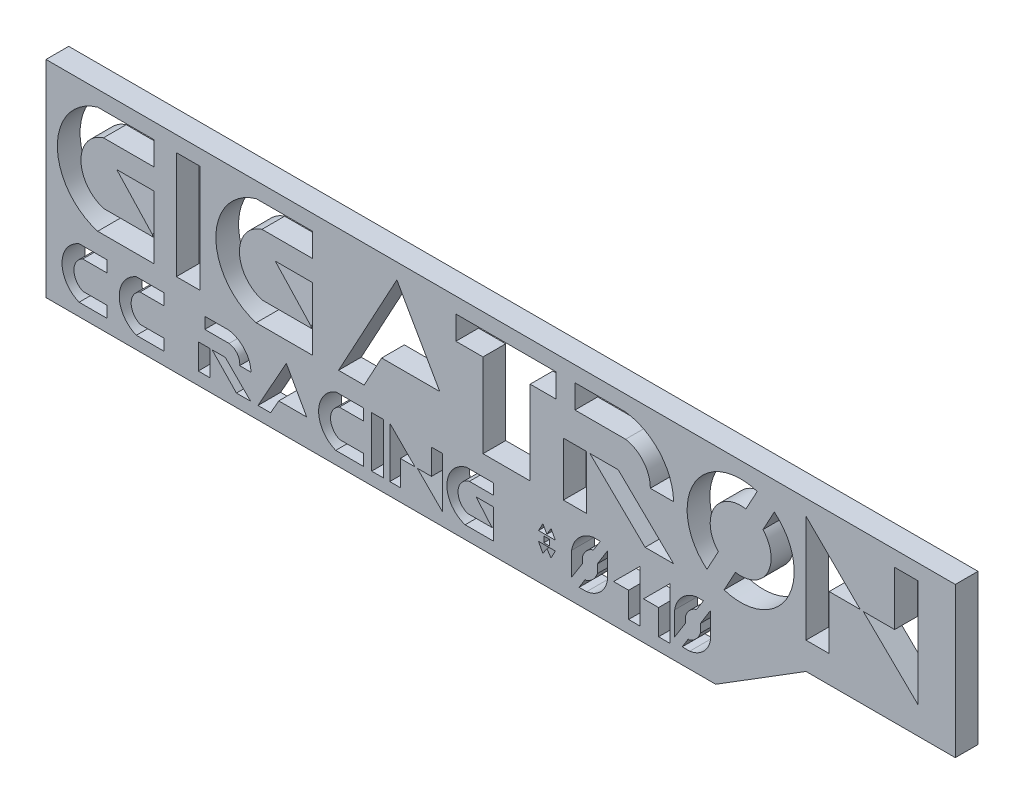
from build123d import *

# Parameters (mm, degrees)
SKETCH1_R           = 2.993573696
SKETCH1_W           = 1.32394335
SKETCH1_H           = 6.009004725
SKETCH1_W_2         = 1.302821584
SKETCH1_H_2         = 3.004502363
SKETCH1_W_3         = 0.319555978
SKETCH1_H_3         = 0.32630106
SKETCH1_W_4         = 0.655123172
SKETCH1_H_4         = 1.417072294
SKETCH1_W_5         = 0.651285311
SKETCH1_H_5         = 2.834144587
BOSS_EXTRUDE1_DEPTH = 1.27
BOSS_EXTRUDE2_DEPTH = 1.27


with BuildPart() as part:
    # Sketch1 → Boss-Extrude1 (new body)
    with BuildSketch(Plane.XY):
        Polygon((0, 8.391688266), (50.853628484, 8.391688266), (50.853628484, 0), (42.503409949, 0), (37.456123998, -3.144988604), (0, -3.144988604), align=None)
        with Locations((38.849727057, 4.508958957)):
            Circle(SKETCH1_R, mode=Mode.SUBTRACT)
        with BuildLine():
            Line((6.036873502, 7.524389986), (6.036873502, 6.203444982))
            Line((6.036873502, 6.203444982), (3.213677316, 6.203444982))
            ThreePointArc((3.213677316, 6.203444982), (1.954325424, 4.493986741), (3.213677316, 2.7845285))
            Line((3.213677316, 2.7845285), (5.943527585, 2.7845285))
            Line((5.943527585, 2.7845285), (5.943527585, 2.895958274))
            Line((5.943527585, 2.895958274), (3.956778712, 5.036610228))
            Line((3.956778712, 5.036610228), (6.036873502, 5.036610228))
            Line((6.036873502, 5.036610228), (6.036873502, 1.515385261))
            Line((6.036873502, 1.515385261), (2.889916286, 1.515385261))
            ThreePointArc((2.889916286, 1.515385261), (0.635162123, 4.519887624), (2.889916286, 7.524389986))
            Line((2.889916286, 7.524389986), (6.036873502, 7.524389986))
        make_face(mode=Mode.SUBTRACT)
        with Locations((7.952259717, 4.519887623)):
            Rectangle(SKETCH1_W, SKETCH1_H, mode=Mode.SUBTRACT)
        with BuildLine():
            Line((12.078277316, 2.7845285), (14.808127585, 2.7845285))
            Line((14.808127585, 2.7845285), (14.808127585, 2.895958274))
            Line((14.808127585, 2.895958274), (12.821378712, 5.036610228))
            Line((12.821378712, 5.036610228), (14.901473502, 5.036610228))
            Line((14.901473502, 5.036610228), (14.901473502, 1.515385261))
            Line((14.901473502, 1.515385261), (11.754516286, 1.515385261))
            ThreePointArc((11.754516286, 1.515385261), (9.499762123, 4.519887624), (11.754516286, 7.524389986))
            Line((11.754516286, 7.524389986), (14.901473502, 7.524389986))
            Line((14.901473502, 7.524389986), (14.901473502, 6.203444982))
            Line((14.901473502, 6.203444982), (12.078277316, 6.203444982))
            ThreePointArc((12.078277316, 6.203444982), (10.818925424, 4.493986741), (12.078277316, 2.7845285))
        make_face(mode=Mode.SUBTRACT)
        Polygon((16.359979161, 1.515385261), (19.621874677, 7.524389986), (22.022205075, 3.31809951), (18.771757662, 3.31809951), (17.793182041, 1.515385261), align=None, mode=Mode.SUBTRACT)
        Polygon((22.922328974, 6.203444982), (22.922328974, 7.524389986), (28.523099902, 7.524389986), (28.523099902, 6.203444982), (27.078426164, 6.203444982), (27.078426164, 1.515385261), (24.439204434, 1.515385261), (24.439204434, 6.203444982), align=None, mode=Mode.SUBTRACT)
        with Locations((29.583857286, 3.017636442)):
            Rectangle(SKETCH1_W_2, SKETCH1_H_2, mode=Mode.SUBTRACT)
        Polygon((30.413320868, 4.519887624), (33.505985808, 1.515385261), (35.098913964, 1.515385261), (32.006249025, 4.519887624), align=None, mode=Mode.SUBTRACT)
        with BuildLine():
            Line((29.583857286, 7.524389986), (29.583857286, 6.203444982))
            Line((29.583857286, 6.203444982), (32.413769336, 6.203444982))
            ThreePointArc((32.413769336, 6.203444982), (33.415640705, 5.616672439), (33.796575511, 4.519887624))
            Line((33.796575511, 4.519887624), (35.09921901, 4.519887624))
            ThreePointArc((35.09921901, 4.519887624), (34.315092007, 6.521418283), (32.413769336, 7.524389986))
            Line((32.413769336, 7.524389986), (29.583857286, 7.524389986))
        make_face(mode=Mode.SUBTRACT)
        Polygon((48.776610429, 1.515385261), (45.710490767, 4.508958957), (47.462703797, 4.508958957), (47.462703797, 7.524389986), (48.776610429, 7.524389986), align=None, mode=Mode.SUBTRACT)
        Polygon((42.503409949, 7.524389986), (42.503409949, 1.515385261), (43.798985644, 1.515385261), (43.798985644, 4.519887624), (45.5405792, 4.519887624), align=None, mode=Mode.SUBTRACT)
        with BuildLine():
            Line((1.851235536, 0.392462234), (3.400726241, 0.392462234))
            Line((3.400726241, 0.392462234), (3.400726241, -0.24370928))
            Line((3.400726241, -0.24370928), (2.056596791, -0.24370928))
            ThreePointArc((2.056596791, -0.24370928), (1.561713986, -1.028584807), (2.063801027, -1.808871412))
            Line((2.063801027, -1.808871412), (3.400726241, -1.808871412))
            Line((3.400726241, -1.808871412), (3.400726241, -2.441682353))
            Line((3.400726241, -2.441682353), (1.851235536, -2.441682353))
            ThreePointArc((1.851235536, -2.441682353), (0.896333841, -1.024610059), (1.851235536, 0.392462234))
        make_face(mode=Mode.SUBTRACT)
        with BuildLine():
            Line((6.601126241, -1.808871412), (6.601126241, -2.441682353))
            Line((6.601126241, -2.441682353), (5.051635536, -2.441682353))
            ThreePointArc((5.051635536, -2.441682353), (4.096733841, -1.024610059), (5.051635536, 0.392462234))
            Line((5.051635536, 0.392462234), (6.601126241, 0.392462234))
            Line((6.601126241, 0.392462234), (6.601126241, -0.24370928))
            Line((6.601126241, -0.24370928), (5.256996791, -0.24370928))
            ThreePointArc((5.256996791, -0.24370928), (4.762113986, -1.028584807), (5.264201027, -1.808871412))
            Line((5.264201027, -1.808871412), (6.601126241, -1.808871412))
        make_face(mode=Mode.SUBTRACT)
        with BuildLine():
            Line((17.751726241, -0.24370928), (16.407596791, -0.24370928))
            ThreePointArc((16.407596791, -0.24370928), (15.912713986, -1.028584807), (16.414801027, -1.808871412))
            Line((16.414801027, -1.808871412), (17.751726241, -1.808871412))
            Line((17.751726241, -1.808871412), (17.751726241, -2.441682353))
            Line((17.751726241, -2.441682353), (16.202235536, -2.441682353))
            ThreePointArc((16.202235536, -2.441682353), (15.247333841, -1.024610059), (16.202235536, 0.392462234))
            Line((16.202235536, 0.392462234), (17.751726241, 0.392462234))
            Line((17.751726241, 0.392462234), (17.751726241, -0.24370928))
        make_face(mode=Mode.SUBTRACT)
        with BuildLine():
            Line((29.395702515, -2.268327676), (29.395702515, -0.684175815))
            ThreePointArc((29.395702515, -0.684175815), (29.799984872, 0.12679969), (30.599762574, 0.552805702))
            Line((30.599762574, 0.552805702), (31.405461203, 0.552805702))
            Line((31.405461203, 0.552805702), (31.405461203, -1.094454097))
            ThreePointArc((31.405461203, -1.094454097), (31.018342623, -1.878748148), (30.235268078, -2.268327676))
            Line((30.235268078, -2.268327676), (29.395702515, -2.268327676))
        make_face(mode=Mode.SUBTRACT)
        with BuildLine():
            Line((35.161502515, -2.268327676), (35.161502515, -0.684175815))
            ThreePointArc((35.161502515, -0.684175815), (35.565784872, 0.12679969), (36.365562574, 0.552805702))
            Line((36.365562574, 0.552805702), (37.171261203, 0.552805702))
            Line((37.171261203, 0.552805702), (37.171261203, -1.094454097))
            ThreePointArc((37.171261203, -1.094454097), (36.784142623, -1.878748148), (36.001068078, -2.268327676))
            Line((36.001068078, -2.268327676), (35.161502515, -2.268327676))
        make_face(mode=Mode.SUBTRACT)
        Polygon((31.74141754, -1.024610059), (33.209272304, 0.443244705), (33.209272304, -2.441682353), (32.583010967, -2.441682353), (32.583010967, -1.024610059), align=None, mode=Mode.SUBTRACT)
        Polygon((34.885672304, 0.443244705), (34.885672304, -2.441682353), (34.259410967, -2.441682353), (34.259410967, -1.024610059), (33.41781754, -1.024610059), align=None, mode=Mode.SUBTRACT)
        Polygon((27.541454171, -1.174755536), (28.484144306, -1.174755536), (28.244477323, -1.638111704), (28.012799239, -1.294589028), (27.789110054, -1.638111704), align=None, mode=Mode.SUBTRACT)
        Polygon((27.541454171, -0.652752526), (27.789110054, -0.204017824), (28.012799239, -0.601164891), (28.244477323, -0.204017824), (28.484144306, -0.652752526), align=None, mode=Mode.SUBTRACT)
        with Locations((28.004810339, -0.931303567)):
            Rectangle(SKETCH1_W_3, SKETCH1_H_3, mode=Mode.SUBTRACT)
        Polygon((11.853157652, -2.441682353), (13.441315959, 0.392462234), (14.582063889, -1.638111704), (13.014868135, -1.638111704), (12.564574454, -2.441682353), align=None, mode=Mode.SUBTRACT)
        with BuildLine():
            Line((10.238187221, -0.24370928), (8.878446155, -0.24370928))
            Line((8.878446155, -0.24370928), (8.878446155, 0.392462234))
            Line((8.878446155, 0.392462234), (10.238187221, 0.392462234))
            ThreePointArc((10.238187221, 0.392462234), (11.104422801, -0.097013015), (11.46430309, -1.024610059))
            Line((11.46430309, -1.024610059), (10.830580281, -1.024610059))
            ThreePointArc((10.830580281, -1.024610059), (10.696113598, -0.51147105), (10.238187221, -0.24370928))
        make_face(mode=Mode.SUBTRACT)
        with Locations((8.842771131, -1.733146206)):
            Rectangle(SKETCH1_W_4, SKETCH1_H_4, mode=Mode.SUBTRACT)
        Polygon((9.287087342, -1.024610059), (10.026533299, -1.024610059), (11.443605593, -2.441682353), (10.649224631, -2.441682353), align=None, mode=Mode.SUBTRACT)
        Polygon((19.225449416, 0.392462234), (20.64252171, -1.024610059), (19.813415322, -1.024610059), (19.813415322, -2.441682353), (19.225449416, -2.441682353), align=None, mode=Mode.SUBTRACT)
        with Locations((18.537981589, -1.02461006)):
            Rectangle(SKETCH1_W_5, SKETCH1_H_5, mode=Mode.SUBTRACT)
        Polygon((21.559221781, 0.394972687), (22.183370204, 0.394972687), (22.183370204, -2.441682353), (20.766297911, -1.024610059), (21.559221781, -1.024610059), align=None, mode=Mode.SUBTRACT)
        with BuildLine():
            Line((23.503540395, 0.394972687), (25.03274344, 0.394972687))
            Line((25.03274344, 0.394972687), (25.03274344, -0.204017824))
            Line((25.03274344, -0.204017824), (23.675899042, -0.204017824))
            ThreePointArc((23.675899042, -0.204017824), (23.045478657, -0.967475765), (23.56735149, -1.808871412))
            Line((23.56735149, -1.808871412), (24.942287147, -1.808871412))
            Line((24.942287147, -1.808871412), (24.055815473, -0.768153037))
            Line((24.055815473, -0.768153037), (25.03274344, -0.768153037))
            Line((25.03274344, -0.768153037), (25.03274344, -2.42573218))
            Line((25.03274344, -2.42573218), (23.44061574, -2.42573218))
            ThreePointArc((23.44061574, -2.42573218), (22.420704147, -0.991925559), (23.503540395, 0.394972687))
        make_face(mode=Mode.SUBTRACT)
    extrude(amount=BOSS_EXTRUDE1_DEPTH)

    # Sketch2 → Boss-Extrude2 (add)
    with BuildSketch(Plane.XY.offset(1.27)):
        with BuildLine():
            Line((29.395702515, -1.992121721), (30.004193826, -1.0284294))
            Line((30.004193826, -1.0284294), (30.004193826, -0.684175815))
            ThreePointArc((30.004193826, -0.684175815), (30.225538207, -0.299522119), (30.599762574, -0.060968299))
            Line((30.599762574, -0.060968299), (30.615064807, -0.060968299))
            Line((30.615064807, -0.060968299), (31.002611888, 0.552805702))
            Line((31.002611888, 0.552805702), (31.405461203, 0.552805702))
            Line((31.405461203, 0.552805702), (31.405461203, 0.298439965))
            Line((31.405461203, 0.298439965), (30.835137182, -0.622259045))
            Line((30.835137182, -0.622259045), (30.835137182, -1.094454097))
            ThreePointArc((30.835137182, -1.094454097), (30.605446102, -1.477755777), (30.235268078, -1.728048406))
            Line((30.235268078, -1.728048406), (30.150159542, -1.728048406))
            Line((30.150159542, -1.728048406), (29.815485296, -2.268327676))
            Line((29.815485296, -2.268327676), (29.395702515, -2.268327676))
            Line((29.395702515, -2.268327676), (29.395702515, -1.992121721))
        make_face()
        with BuildLine():
            Line((36.851278394, 1.967702451), (37.807455754, 1.448656322))
            Line((37.807455754, 1.448656322), (38.557205403, 2.829831519))
            ThreePointArc((38.557205403, 2.829831519), (40.347674106, 3.695821509), (40.098426071, 5.669040265))
            Line((40.098426071, 5.669040265), (40.84817572, 7.050215462))
            Line((40.84817572, 7.050215462), (39.89199836, 7.569261591))
            Line((39.89199836, 7.569261591), (39.142248711, 6.188086394))
            ThreePointArc((39.142248711, 6.188086394), (37.351780008, 5.322096404), (37.601028043, 3.348877648))
            Line((37.601028043, 3.348877648), (36.851278394, 1.967702451))
        make_face()
        with BuildLine():
            Line((35.581285296, -2.268327676), (35.915959542, -1.728048406))
            Line((35.915959542, -1.728048406), (36.001068078, -1.728048406))
            ThreePointArc((36.001068078, -1.728048406), (36.371246102, -1.477755777), (36.600937182, -1.094454097))
            Line((36.600937182, -1.094454097), (36.600937182, -0.622259045))
            Line((36.600937182, -0.622259045), (37.171261203, 0.298439965))
            Line((37.171261203, 0.298439965), (37.171261203, 0.552805702))
            Line((37.171261203, 0.552805702), (36.768411888, 0.552805702))
            Line((36.768411888, 0.552805702), (36.380864807, -0.060968299))
            Line((36.380864807, -0.060968299), (36.365562574, -0.060968299))
            ThreePointArc((36.365562574, -0.060968299), (35.991338207, -0.299522119), (35.769993826, -0.684175815))
            Line((35.769993826, -0.684175815), (35.769993826, -1.0284294))
            Line((35.769993826, -1.0284294), (35.161502515, -1.992121721))
            Line((35.161502515, -1.992121721), (35.161502515, -2.268327676))
            Line((35.161502515, -2.268327676), (35.581285296, -2.268327676))
        make_face()
    extrude(amount=-BOSS_EXTRUDE2_DEPTH)


solid = part.part
